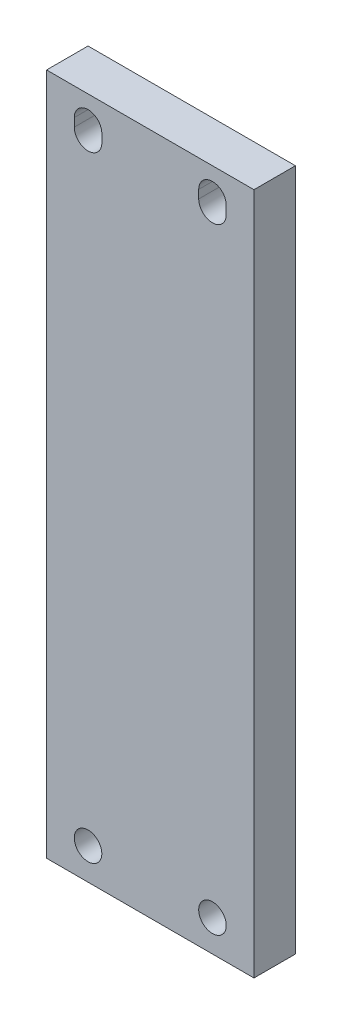
from build123d import *

# Parameters (mm, degrees)
SKETCH1_W_MOCK_PCB_W     = 63.5
SKETCH1_W_MOCK_PCB_H     = 209.042
BOSS_EXTRUDE1_DEPTH      = 6.35
F_5_16_CLEARANCE_HOLE1_D = 8.4328
CUT_EXTRUDE1_DEPTH       = 13.7


with BuildPart() as part:
    # Sketch1 w/mock PCB → Boss-Extrude1 (new body, symmetric)
    with BuildSketch(Plane.XY):
        Rectangle(SKETCH1_W_MOCK_PCB_W, SKETCH1_W_MOCK_PCB_H)
    extrude(amount=BOSS_EXTRUDE1_DEPTH, both=True)

    # 5/16 Clearance Hole1 (through all)
    with Locations(Plane.XY.offset(6.35)):
        with Locations((-19.05, -94.869), (19.05, -94.869)):
            Hole(F_5_16_CLEARANCE_HOLE1_D / 2)

    # Sketch3 → Cut-Extrude1 (cut, through all)
    with BuildSketch(Plane.XY.offset(6.35)):
        with BuildLine():
            Line((-23.2664, 93.599), (-23.2664, 96.139))
            ThreePointArc((-23.2664, 96.139), (-19.05, 100.3554), (-14.8336, 96.139))
            Line((-14.8336, 96.139), (-14.8336, 93.599))
            ThreePointArc((-14.8336, 93.599), (-19.05, 89.3826), (-23.2664, 93.599))
        make_face()
        with BuildLine():
            Line((23.2664, 93.599), (23.2664, 96.139))
            ThreePointArc((23.2664, 96.139), (19.05, 100.3554), (14.8336, 96.139))
            Line((14.8336, 96.139), (14.8336, 93.599))
            ThreePointArc((14.8336, 93.599), (19.05, 89.3826), (23.2664, 93.599))
        make_face()
    extrude(amount=-CUT_EXTRUDE1_DEPTH, mode=Mode.SUBTRACT)


solid = part.part
